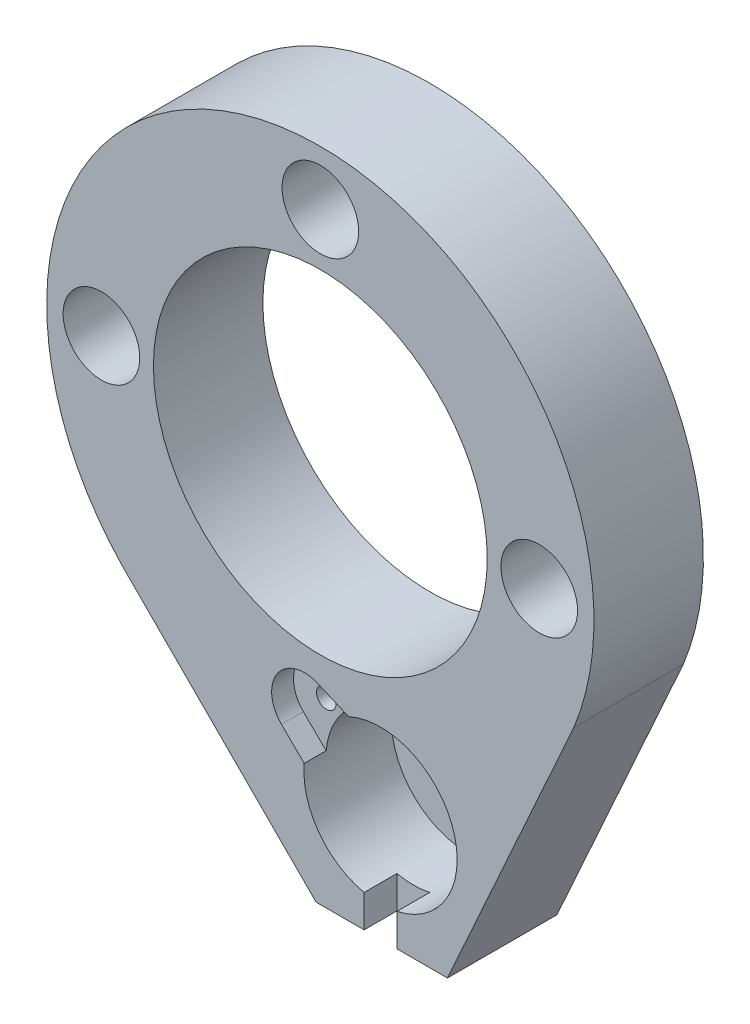
from build123d import *

# Parameters (mm, degrees)
EXTRUDE1_DEPTH                 = 10
SKETCH2_R                      = 15.25
EXTRUDE2_DEPTH                 = 11
F_5_3_5_3_DIAMETER_HOLE1_D     = 5.3
F_5_3_5_3_DIAMETER_HOLE1_DEPTH = 15
SKETCH4_R                      = 7
EXTRUDE3_DEPTH                 = 8
SKETCH5_W                      = 3
SKETCH5_H                      = 2.962602834
EXTRUDE4_DEPTH                 = 3
SKETCH6_W                      = 1
SKETCH6_H                      = 2.1
EXTRUDE5_DEPTH                 = 3
SKETCH7_R                      = 0.9
EXTRUDE6_DEPTH                 = 5
EXTRUDE7_DEPTH                 = 2
SKETCH9_R                      = 1.5
EXTRUDE9_DEPTH                 = 11
SKETCH10_R                     = 3.5
EXTRUDE10_DEPTH                = 5


with BuildPart() as part:
    # Sketch1 → Extrude1 (new body)
    with BuildSketch(Plane.XY):
        with BuildLine():
            Line((-0.385076955, -35), (11.614923045, -35))
            Line((11.614923045, -35), (23.167030313, -9.396207025))
            ThreePointArc((23.167030313, -9.396207025), (-4.655667218, 24.562670106), (-18.121718507, -17.222175192))
            Line((-18.121718507, -17.222175192), (-0.385076955, -35))
        make_face()
    extrude(amount=EXTRUDE1_DEPTH)

    # Sketch2 → Extrude2 (cut, through all)
    with BuildSketch(Plane.XY.offset(10)):
        Circle(SKETCH2_R)
    extrude(amount=-EXTRUDE2_DEPTH, mode=Mode.SUBTRACT)

    # Ø5.3 (5.3) Diameter Hole1
    with Locations(Plane(origin=(5.5, -25.2, 10), x_dir=(1, 0, 0), z_dir=(0, 0, 1))):
        with Locations((0, 0)):
            Hole(F_5_3_5_3_DIAMETER_HOLE1_D / 2, depth=F_5_3_5_3_DIAMETER_HOLE1_DEPTH)

    # Sketch4 → Extrude3 (cut)
    with BuildSketch(Plane.XY.offset(10)):
        with Locations((5.5, -25.2)):
            Circle(SKETCH4_R)
    extrude(amount=-EXTRUDE3_DEPTH, mode=Mode.SUBTRACT)

    # Sketch5 → Extrude4 (cut)
    with BuildSketch(Plane.XY.offset(10)):
        with Locations((5.5, -33.518698583)):
            Rectangle(SKETCH5_W, SKETCH5_H)
    extrude(amount=-EXTRUDE4_DEPTH, mode=Mode.SUBTRACT)

    # Sketch6 → Extrude5 (cut, through all)
    with BuildSketch(Plane.XY.offset(2)):
        with Locations((0, -24.741008814)):
            Rectangle(SKETCH6_W, SKETCH6_H)
    extrude(amount=-EXTRUDE5_DEPTH, mode=Mode.SUBTRACT)

    # Sketch7 → Extrude6 (cut)
    with BuildSketch(Plane.XY.offset(10)):
        with Locations((-1.44988107, -20.370788479)):
            Circle(SKETCH7_R)
    extrude(amount=-EXTRUDE6_DEPTH, mode=Mode.SUBTRACT)

    # Sketch8 → Extrude7 (cut)
    with BuildSketch(Plane.XY.offset(10)):
        with BuildLine():
            Line((-3.55371741, -22.509449896), (-1.470560637, -24.558685407))
            Line((-1.470560637, -24.558685407), (2.590549038, -18.833282235))
            Line((2.590549038, -18.833282235), (-0.272375103, -17.611535012))
            ThreePointArc((-0.272375103, -17.611535012), (-3.942252339, -18.701032372), (-3.55371741, -22.509449896))
        make_face()
    extrude(amount=-EXTRUDE7_DEPTH, mode=Mode.SUBTRACT)

    # Sketch9 → Extrude9 (cut, through all)
    with BuildSketch(Plane.XY):
        with Locations((0, 20)):
            Circle(SKETCH9_R)
        with Locations((-20, 0)):
            Circle(SKETCH9_R)
        with Locations((20, 0)):
            Circle(SKETCH9_R)
    extrude(amount=EXTRUDE9_DEPTH, mode=Mode.SUBTRACT)

    # Sketch10 → Extrude10 (cut)
    with BuildSketch(Plane.XY.offset(10)):
        with Locations((-20, 0)):
            Circle(SKETCH10_R)
        with Locations((0, 20)):
            Circle(SKETCH10_R)
        with Locations((20, 0)):
            Circle(SKETCH10_R)
    extrude(amount=-EXTRUDE10_DEPTH, mode=Mode.SUBTRACT)


solid = part.part
